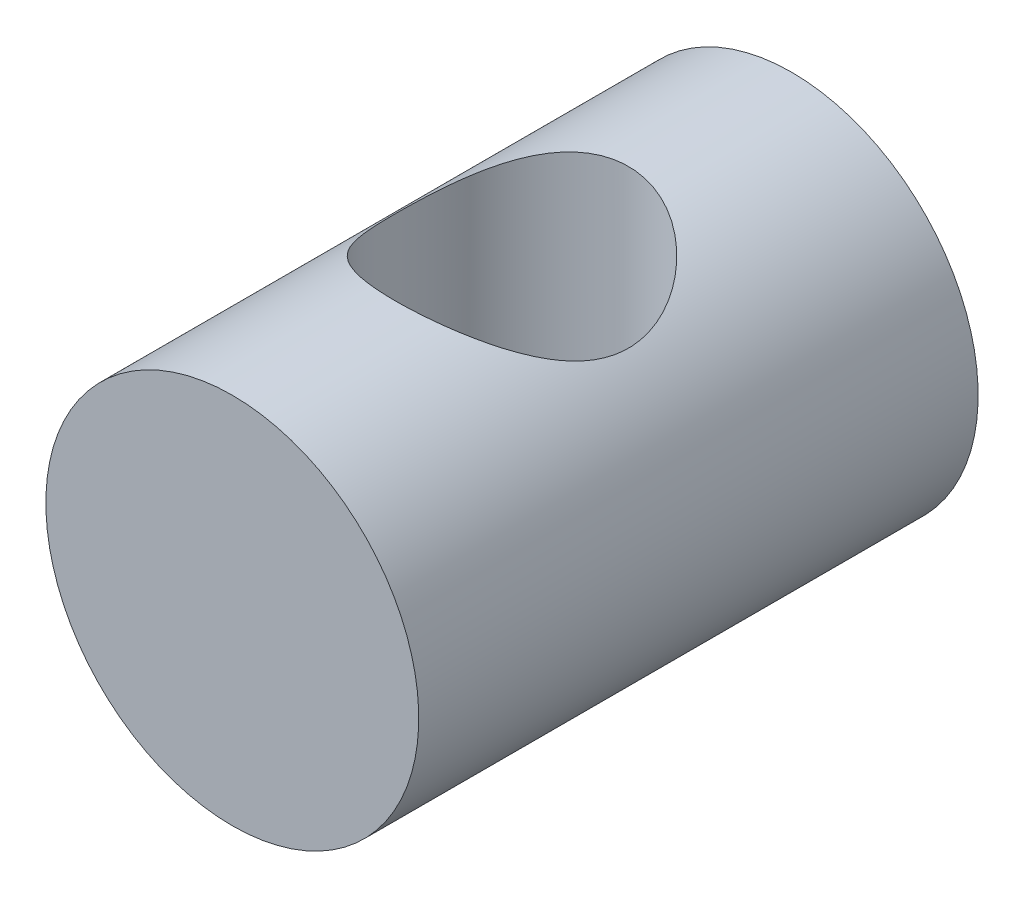
from build123d import *

# Parameters (mm, degrees)
CROQUIS2_W                 = 12
CROQUIS2_H                 = 4
CROQUIS3_R                 = 2.5
CORTAR_EXTRUIR1_DEPTH      = 5
CORTAR_EXTRUIR1_DEPTH_BACK = 5


with BuildPart() as part:
    # Croquis2 → Revolución5 (revolve)
    with BuildSketch(Plane(origin=(0, 0, 0), x_dir=(0, 0, -1), z_dir=(1, 0, 0))):
        with Locations((0, 2)):
            Rectangle(CROQUIS2_W, CROQUIS2_H)
    revolve(axis=Axis((0, 0, 6), (0, 0, -1)))

    # Croquis3 → Cortar-Extruir1 (cut, two sides)
    with BuildSketch(Plane(origin=(0, 0, 0), x_dir=(1, 0, 0), z_dir=(0, 1, 0))) as cortar_extruir1_sk:
        Circle(CROQUIS3_R)
    extrude(amount=CORTAR_EXTRUIR1_DEPTH, mode=Mode.SUBTRACT)
    extrude(cortar_extruir1_sk.sketch, amount=-CORTAR_EXTRUIR1_DEPTH_BACK, mode=Mode.SUBTRACT)


solid = part.part
